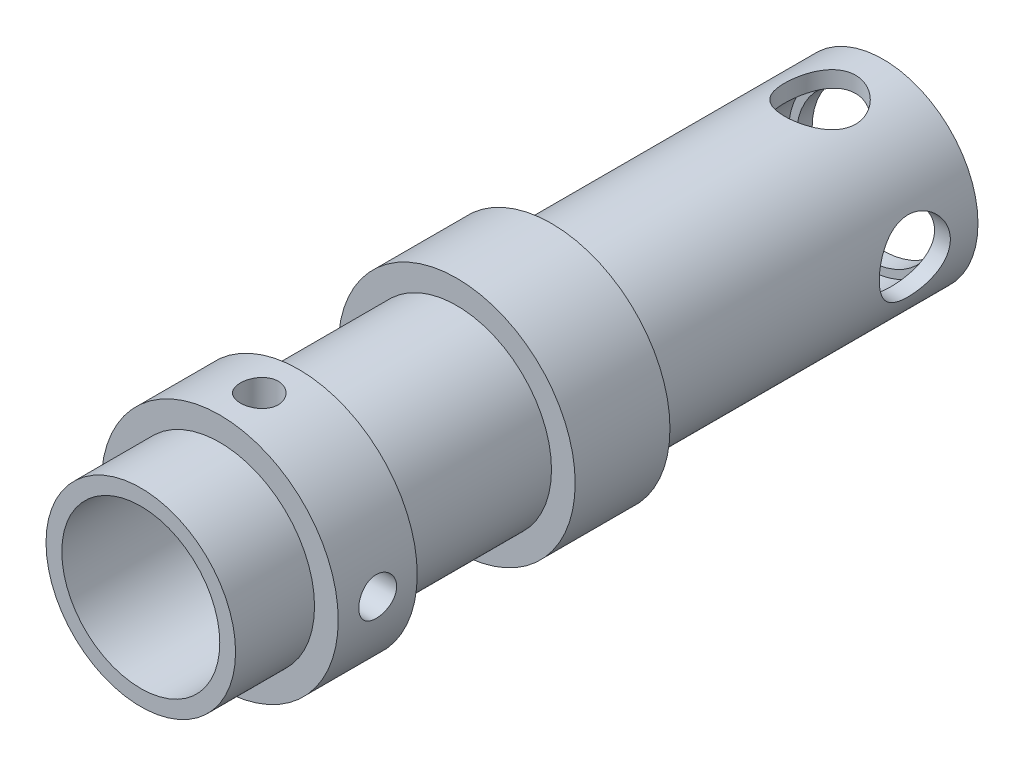
from build123d import *

# Parameters (mm, degrees)
ESQUISSE1_R                = 6
ESQUISSE1_R_2              = 5
BOSS_EXTRU_1_DEPTH         = 21
ESQUISSE2_R                = 6
ESQUISSE2_R_2              = 4.5
BOSS_EXTRU_2_DEPTH         = 1
ESQUISSE3_R                = 7.5
ESQUISSE3_R_2              = 5
BOSS_EXTRU_3_DEPTH         = 6
ESQUISSE4_R                = 6
ESQUISSE4_R_2              = 5
BOSS_EXTRU_4_DEPTH         = 10
ESQUISSE7_R                = 7.5
ESQUISSE7_R_2              = 5
BOSS_EXTRU_7_DEPTH         = 5
ESQUISSE8_R                = 6
ESQUISSE8_R_2              = 5
BOSS_EXTRU_8_DEPTH         = 5
D_GAGEMENT_M22_D           = 2.4
D_GAGEMENT_M22_ON_FACE_2_D = 2.4
D_GAGEMENT_M41_D           = 4.5
D_GAGEMENT_M41_ON_FACE_2_D = 4.5


with BuildPart() as part:
    # Esquisse1 → Boss.-Extru.1 (new body)
    with BuildSketch(Plane.XY):
        Circle(ESQUISSE1_R)
        Circle(ESQUISSE1_R_2, mode=Mode.SUBTRACT)
    extrude(amount=BOSS_EXTRU_1_DEPTH)

    # Esquisse2 → Boss.-Extru.2 (add)
    with BuildSketch(Plane(origin=(0, 0, 0), x_dir=(-1, 0, 0), z_dir=(0, 0, -1))):
        Circle(ESQUISSE2_R)
        Circle(ESQUISSE2_R_2, mode=Mode.SUBTRACT)
    extrude(amount=-BOSS_EXTRU_2_DEPTH)

    # Esquisse3 → Boss.-Extru.3 (add)
    with BuildSketch(Plane.XY.offset(21)):
        Circle(ESQUISSE3_R)
        Circle(ESQUISSE3_R_2, mode=Mode.SUBTRACT)
    extrude(amount=BOSS_EXTRU_3_DEPTH)

    # Esquisse4 → Boss.-Extru.4 (add)
    with BuildSketch(Plane.XY.offset(27)):
        Circle(ESQUISSE4_R)
        Circle(ESQUISSE4_R_2, mode=Mode.SUBTRACT)
    extrude(amount=BOSS_EXTRU_4_DEPTH)

    # Esquisse7 → Boss.-Extru.7 (add)
    with BuildSketch(Plane.XY.offset(37)):
        Circle(ESQUISSE7_R)
        Circle(ESQUISSE7_R_2, mode=Mode.SUBTRACT)
    extrude(amount=BOSS_EXTRU_7_DEPTH)

    # Esquisse8 → Boss.-Extru.8 (add)
    with BuildSketch(Plane.XY.offset(42)):
        Circle(ESQUISSE8_R)
        Circle(ESQUISSE8_R_2, mode=Mode.SUBTRACT)
    extrude(amount=BOSS_EXTRU_8_DEPTH)

    # Dégagement M22 (through all)
    with Locations(Plane(origin=(0, -7.5, 39.5), x_dir=(-1, 0, 0), z_dir=(0, -1, 0))):
        with Locations((0, 0)):
            Hole(D_GAGEMENT_M22_D / 2)

    # Dégagement M22 on face 2 (through all)
    with Locations(Plane(origin=(7.5, 0, 39.5), x_dir=(0, 0, 1), z_dir=(1, 0, 0))):
        with Locations((0, 0)):
            Hole(D_GAGEMENT_M22_ON_FACE_2_D / 2)

    # Dégagement M41 (through all)
    with Locations(Plane(origin=(6, 0, 4), x_dir=(0, 0, 1), z_dir=(1, 0, 0))):
        with Locations((0, 0)):
            Hole(D_GAGEMENT_M41_D / 2)

    # Dégagement M41 on face 2 (through all)
    with Locations(Plane(origin=(0, 6, 4), x_dir=(0, 0, 1), z_dir=(0, 1, 0))):
        with Locations((0, 0)):
            Hole(D_GAGEMENT_M41_ON_FACE_2_D / 2)


solid = part.part
